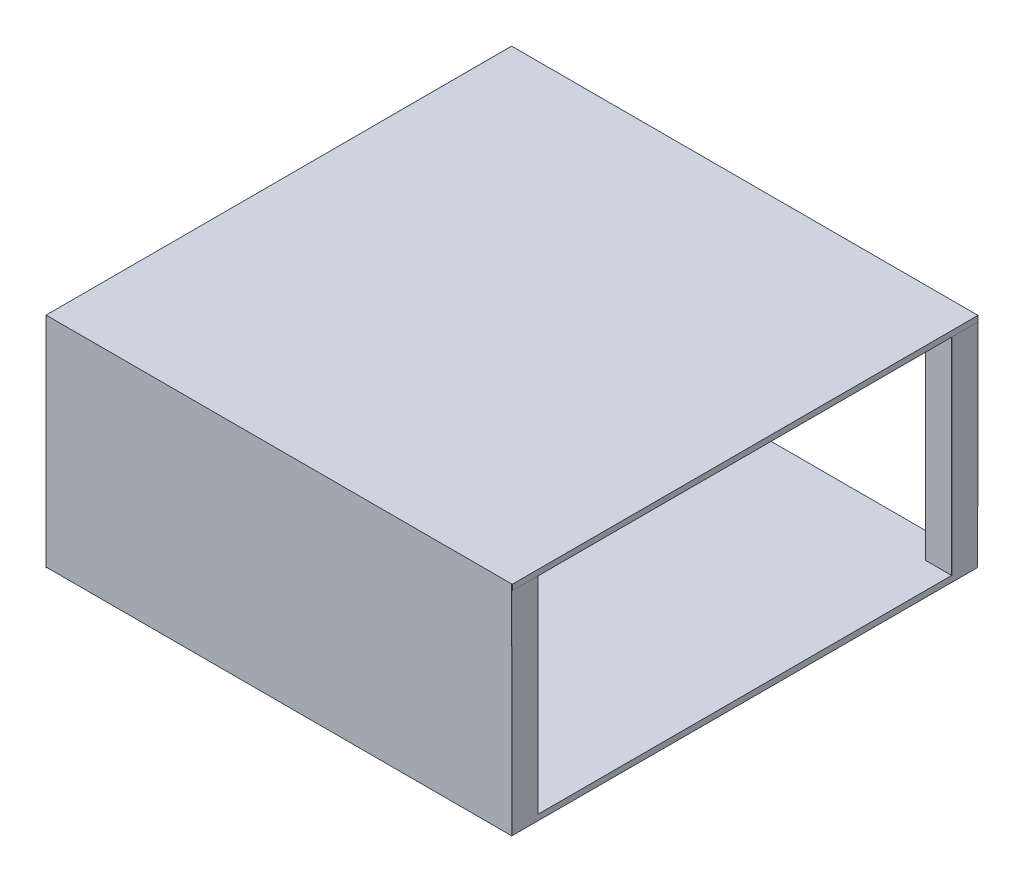
from build123d import *

# Parameters (mm, degrees)
BOSS_EXTRUDE1_DEPTH  = 11.1125
SKETCH1_5_W          = 50.8
SKETCH1_5_H          = 50.8
BOSS_EXTRUDE3_DEPTH  = 417.5125
SKETCH1_6_W          = 50.8
SKETCH1_6_H          = 50.8
BOSS_EXTRUDE4_DEPTH  = 417.5125
SKETCH1_7_W          = 50.8
SKETCH1_7_H          = 50.8
BOSS_EXTRUDE5_DEPTH  = 417.5125
SKETCH1_8_W          = 50.8
SKETCH1_8_H          = 50.8
BOSS_EXTRUDE6_DEPTH  = 417.5125
SKETCH2_W            = 915.815141898
SKETCH2_H            = 914.4
BOSS_EXTRUDE8_DEPTH  = 11.1125
SKETCH3_W            = 914.440346881
SKETCH3_H            = 428.625
BOSS_EXTRUDE9_DEPTH  = 0.4375
SKETCH4_W            = 814.910119316
SKETCH4_H            = 406.4
BOSS_EXTRUDE13_DEPTH = 0.4375
BOSS_EXTRUDE21_DEPTH = 0.4375


with BuildPart() as part:
    # Sketch1 → Boss-Extrude1 (new body)
    with BuildSketch(Plane(origin=(0, 0, 0), x_dir=(1, 0, 0), z_dir=(0, 1, 0))):
        Polygon((-406.4, 406.4), (-457.2, 406.4), (-457.2, -406.4), (-406.4, -406.4), (-406.4, -457.2), (406.4, -457.2), (406.4, -406.4), (457.2, -406.4), (457.2, 406.4), (406.4, 406.4), (406.4, 457.2), (-406.4, 457.2), align=None)
    extrude(amount=BOSS_EXTRUDE1_DEPTH)

    # Sketch1_5 → Boss-Extrude3 (add)
    with BuildSketch(Plane(origin=(0, 0, 0), x_dir=(1, 0, 0), z_dir=(0, 1, 0))):
        with Locations((431.8, -431.8)):
            Rectangle(SKETCH1_5_W, SKETCH1_5_H)
    extrude(amount=BOSS_EXTRUDE3_DEPTH)

    # Sketch1_6 → Boss-Extrude4 (add)
    with BuildSketch(Plane(origin=(0, 0, 0), x_dir=(1, 0, 0), z_dir=(0, 1, 0))):
        with Locations((-431.8, -431.8)):
            Rectangle(SKETCH1_6_W, SKETCH1_6_H)
    extrude(amount=BOSS_EXTRUDE4_DEPTH)

    # Sketch1_7 → Boss-Extrude5 (add)
    with BuildSketch(Plane(origin=(0, 0, 0), x_dir=(1, 0, 0), z_dir=(0, 1, 0))):
        with Locations((431.8, 431.8)):
            Rectangle(SKETCH1_7_W, SKETCH1_7_H)
    extrude(amount=BOSS_EXTRUDE5_DEPTH)

    # Sketch1_8 → Boss-Extrude6 (add)
    with BuildSketch(Plane(origin=(0, 0, 0), x_dir=(1, 0, 0), z_dir=(0, 1, 0))):
        with Locations((-431.8, 431.8)):
            Rectangle(SKETCH1_8_W, SKETCH1_8_H)
    extrude(amount=BOSS_EXTRUDE6_DEPTH)

    # Sketch2 → Boss-Extrude8 (add)
    with BuildSketch(Plane(origin=(0, 417.5125, 0), x_dir=(1, 0, 0), z_dir=(0, 1, 0))):
        with Locations((0.707570949, 0)):
            Rectangle(SKETCH2_W, SKETCH2_H)
    extrude(amount=BOSS_EXTRUDE8_DEPTH)

    # Sketch3 → Boss-Extrude9 (add)
    with BuildSketch(Plane.XY.offset(457.2)):
        with Locations((0.020173441, 214.3125)):
            Rectangle(SKETCH3_W, SKETCH3_H)
    extrude(amount=BOSS_EXTRUDE9_DEPTH)

    # Sketch4 → Boss-Extrude13 (add)
    with BuildSketch(Plane(origin=(457.2, 0, 0), x_dir=(0, 0, -1), z_dir=(1, 0, 0))):
        Polygon((-457.2, 428.625), (-457.6375, 0), (457.580376967, -0.934168145), (458.017876967, 427.690831855), align=None)
        with Locations((1.055059658, 214.3125)):
            Rectangle(SKETCH4_W, SKETCH4_H, mode=Mode.SUBTRACT)
    extrude(amount=BOSS_EXTRUDE13_DEPTH)

    # Sketch10 → Boss-Extrude21 (add)
    with BuildSketch(Plane.ZY.offset(457.2)):
        Polygon((-457.2, 428.625), (-457.580376967, -0.934168145), (456.953407178, -1.743992758), (457.333784145, 427.815175387), align=None)
    extrude(amount=BOSS_EXTRUDE21_DEPTH)


solid = part.part
